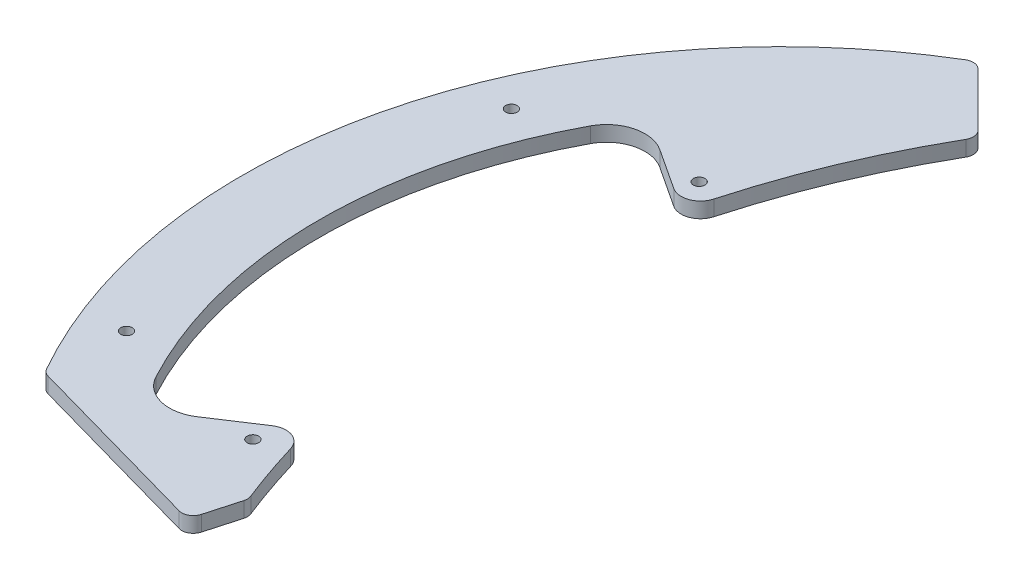
from build123d import *

# Parameters (mm, degrees)
SKETCH1_R               = 140
BOSS_EXTRUDE1_DEPTH     = 4
CUT_EXTRUDE1_REACH      = 6
CUT_EXTRUDE3_REACH      = 6
SKETCH19_R              = 1.5
CUT_EXTRUDE4_REACH      = 6
FILLET2_R               = 10
CUT_EXTRUDE8_DEPTH      = 1
CUT_EXTRUDE8_DEPTH_BACK = 5
CUT_EXTRUDE9_REACH      = 6
FILLET4_R               = 5
FILLET6_R               = 10
CUT_EXTRUDE10_REACH     = 6
SKETCH25_R              = 1.5
FILLET5_R               = 3


with BuildPart() as part:
    # Sketch1 → Boss-Extrude1 (new body)
    with BuildSketch(Plane(origin=(0, 0, 0), x_dir=(1, 0, 0), z_dir=(0, 1, 0))):
        Circle(SKETCH1_R)
    extrude(amount=BOSS_EXTRUDE1_DEPTH)

    # Sketch17 → Cut-Extrude1 (cut, up to next)
    with BuildSketch(Plane.XZ, mode=Mode.PRIVATE) as cut_extrude1_sk1:
        Polygon((-50, 90), (-121.24355653, 70), (-121.24355653, 140), (121.24355653, 140), (121.24355653, 70), (50, 90), align=None)
    cut_extrude1_tool1 = extrude(cut_extrude1_sk1.sketch, amount=-CUT_EXTRUDE1_REACH, mode=Mode.PRIVATE) & part.part
    add(cut_extrude1_tool1.solids().sort_by_distance((0, 0, 111.669853))[0], mode=Mode.SUBTRACT)

    # Sketch19 → Cut-Extrude3 (cut, up to next)
    with BuildSketch(Plane(origin=(0, 4, 0), x_dir=(1, 0, 0), z_dir=(0, 1, 0)), mode=Mode.PRIVATE) as cut_extrude3_sk1:
        with Locations((-79.195959493, -57.982756057)):
            Circle(SKETCH19_R)
    cut_extrude3_tool1 = extrude(cut_extrude3_sk1.sketch, amount=-CUT_EXTRUDE3_REACH, mode=Mode.PRIVATE) & part.part
    add(cut_extrude3_tool1.solids().sort_by_distance((-79.195959, 4, 57.982756))[0], mode=Mode.SUBTRACT)
    # Sketch19 → Cut-Extrude3 (cut, up to next)
    with BuildSketch(Plane(origin=(0, 4, 0), x_dir=(1, 0, 0), z_dir=(0, 1, 0)), mode=Mode.PRIVATE) as cut_extrude3_sk2:
        with Locations((-79.195959493, 57.982756057)):
            Circle(SKETCH19_R)
    cut_extrude3_tool2 = extrude(cut_extrude3_sk2.sketch, amount=-CUT_EXTRUDE3_REACH, mode=Mode.PRIVATE) & part.part
    add(cut_extrude3_tool2.solids().sort_by_distance((-79.195959, 4, -57.982756))[0], mode=Mode.SUBTRACT)
    # Sketch19 → Cut-Extrude3 (cut, up to next)
    with BuildSketch(Plane(origin=(0, 4, 0), x_dir=(1, 0, 0), z_dir=(0, 1, 0)), mode=Mode.PRIVATE) as cut_extrude3_sk3:
        with Locations((79.195959493, 57.982756057)):
            Circle(SKETCH19_R)
    cut_extrude3_tool3 = extrude(cut_extrude3_sk3.sketch, amount=-CUT_EXTRUDE3_REACH, mode=Mode.PRIVATE) & part.part
    add(cut_extrude3_tool3.solids().sort_by_distance((79.195959, 4, -57.982756))[0], mode=Mode.SUBTRACT)
    # Sketch19 → Cut-Extrude3 (cut, up to next)
    with BuildSketch(Plane(origin=(0, 4, 0), x_dir=(1, 0, 0), z_dir=(0, 1, 0)), mode=Mode.PRIVATE) as cut_extrude3_sk4:
        with Locations((79.195959493, -57.982756057)):
            Circle(SKETCH19_R)
    cut_extrude3_tool4 = extrude(cut_extrude3_sk4.sketch, amount=-CUT_EXTRUDE3_REACH, mode=Mode.PRIVATE) & part.part
    add(cut_extrude3_tool4.solids().sort_by_distance((79.195959, 4, 57.982756))[0], mode=Mode.SUBTRACT)
    # Sketch19 → Cut-Extrude3 (cut, up to next)
    with BuildSketch(Plane(origin=(0, 4, 0), x_dir=(1, 0, 0), z_dir=(0, 1, 0)), mode=Mode.PRIVATE) as cut_extrude3_sk5:
        with Locations((-57.982756057, 79.195959493)):
            Circle(SKETCH19_R)
    cut_extrude3_tool5 = extrude(cut_extrude3_sk5.sketch, amount=-CUT_EXTRUDE3_REACH, mode=Mode.PRIVATE) & part.part
    add(cut_extrude3_tool5.solids().sort_by_distance((-57.982756, 4, -79.195959))[0], mode=Mode.SUBTRACT)
    # Sketch19 → Cut-Extrude3 (cut, up to next)
    with BuildSketch(Plane(origin=(0, 4, 0), x_dir=(1, 0, 0), z_dir=(0, 1, 0)), mode=Mode.PRIVATE) as cut_extrude3_sk6:
        with Locations((57.982756057, 79.195959493)):
            Circle(SKETCH19_R)
    cut_extrude3_tool6 = extrude(cut_extrude3_sk6.sketch, amount=-CUT_EXTRUDE3_REACH, mode=Mode.PRIVATE) & part.part
    add(cut_extrude3_tool6.solids().sort_by_distance((57.982756, 4, -79.195959))[0], mode=Mode.SUBTRACT)
    # Sketch19 → Cut-Extrude3 (cut, up to next)
    with BuildSketch(Plane(origin=(0, 4, 0), x_dir=(1, 0, 0), z_dir=(0, 1, 0)), mode=Mode.PRIVATE) as cut_extrude3_sk7:
        with Locations((57.982756057, -79.195959493)):
            Circle(SKETCH19_R)
    cut_extrude3_tool7 = extrude(cut_extrude3_sk7.sketch, amount=-CUT_EXTRUDE3_REACH, mode=Mode.PRIVATE) & part.part
    add(cut_extrude3_tool7.solids().sort_by_distance((57.982756, 4, 79.195959))[0], mode=Mode.SUBTRACT)
    # Sketch19 → Cut-Extrude3 (cut, up to next)
    with BuildSketch(Plane(origin=(0, 4, 0), x_dir=(1, 0, 0), z_dir=(0, 1, 0)), mode=Mode.PRIVATE) as cut_extrude3_sk8:
        with Locations((-57.982756057, -79.195959493)):
            Circle(SKETCH19_R)
    cut_extrude3_tool8 = extrude(cut_extrude3_sk8.sketch, amount=-CUT_EXTRUDE3_REACH, mode=Mode.PRIVATE) & part.part
    add(cut_extrude3_tool8.solids().sort_by_distance((-57.982756, 4, 79.195959))[0], mode=Mode.SUBTRACT)

    # Sketch20 → Cut-Extrude4 (cut, up to next)
    with BuildSketch(Plane(origin=(0, 4, 0), x_dir=(1, 0, 0), z_dir=(0, 1, 0)), mode=Mode.PRIVATE) as cut_extrude4_sk1:
        Polygon((-498.316459894, 549.560016424), (-70, 121.24355653), (-50, 101.24355653), (50, 101.24355653), (70, 121.24355653), (498.316459894, 549.560016424), (498.316459894, 1761.021909565), (-498.316459894, 1761.021909565), align=None)
    cut_extrude4_tool1 = extrude(cut_extrude4_sk1.sketch, amount=-CUT_EXTRUDE4_REACH, mode=Mode.PRIVATE) & part.part
    add(cut_extrude4_tool1.solids().sort_by_distance((0, 4, -1025.243605))[0], mode=Mode.SUBTRACT)

    # Fillet2
    fillet2_edges = [part.edges().sort_by_distance(p)[0] for p in [
        (50, 2, -101.24355653),
        (-50, 2, -101.24355653),
    ]]
    fillet(fillet2_edges, radius=FILLET2_R)

    # Sketch23 → Cut-Extrude8 (cut, two sides)
    with BuildSketch(Plane(origin=(0, 4, 0), x_dir=(1, 0, 0), z_dir=(0, 1, 0))) as cut_extrude8_sk:
        with BuildLine():
            Line((261.924008605, 637.436261059), (-52.928932188, 104.172488718))
            ThreePointArc((-52.928932188, 104.172488718), (-80.130232259, 17.669229552), (-66.336519501, -71.95475195))
            Line((-66.336519501, -71.95475195), (-73.189737717, -96.367133919))
            Line((-73.189737717, -96.367133919), (-240.56703475, -692.594830068))
            Line((-240.56703475, -692.594830068), (918.053550165, -1130.326301498))
            Line((918.053550165, -1130.326301498), (1420.54459352, 199.704789628))
            Line((1420.54459352, 199.704789628), (261.924008605, 637.436261059))
        make_face()
    extrude(amount=CUT_EXTRUDE8_DEPTH, mode=Mode.SUBTRACT)
    extrude(cut_extrude8_sk.sketch, amount=-CUT_EXTRUDE8_DEPTH_BACK, mode=Mode.SUBTRACT)

    # Sketch24 → Cut-Extrude9 (cut, up to next)
    with BuildSketch(Plane(origin=(0, 4, 0), x_dir=(1, 0, 0), z_dir=(0, 1, 0)), mode=Mode.PRIVATE) as cut_extrude9_sk1:
        with BuildLine():
            Line((0, 0), (-100.308962252, 65.864346136))
            ThreePointArc((-100.308962252, 65.864346136), (-120, 0), (-100.308962252, -65.864346136))
            Line((-100.308962252, -65.864346136), (0, 0))
        make_face()
    cut_extrude9_tool1 = extrude(cut_extrude9_sk1.sketch, amount=-CUT_EXTRUDE9_REACH, mode=Mode.PRIVATE) & part.part
    add(cut_extrude9_tool1.solids().sort_by_distance((-75.574375, 4, 0))[0], mode=Mode.SUBTRACT)

    # Fillet4
    fillet4_edges = [part.edges().sort_by_distance(p)[0] for p in [
        (-74.063830686, 2, 48.63140512),
        (-75.142204111, 2, -49.339481038),
    ]]
    fillet(fillet4_edges, radius=FILLET4_R)

    # Fillet6
    fillet6_edges = [part.edges().sort_by_distance(p)[0] for p in [
        (-100.308962252, 2, 65.864346136),
        (-100.308962252, 2, -65.864346136),
    ]]
    fillet(fillet6_edges, radius=FILLET6_R)

    # Sketch25 → Cut-Extrude10 (cut, up to next)
    with BuildSketch(Plane(origin=(0, 4, 0), x_dir=(1, 0, 0), z_dir=(0, 1, 0)), mode=Mode.PRIVATE) as cut_extrude10_sk1:
        with Locations((-120, 50)):
            Circle(SKETCH25_R)
    cut_extrude10_tool1 = extrude(cut_extrude10_sk1.sketch, amount=-CUT_EXTRUDE10_REACH, mode=Mode.PRIVATE) & part.part
    add(cut_extrude10_tool1.solids().sort_by_distance((-120, 4, -50))[0], mode=Mode.SUBTRACT)
    # Sketch25 → Cut-Extrude10 (cut, up to next)
    with BuildSketch(Plane(origin=(0, 4, 0), x_dir=(1, 0, 0), z_dir=(0, 1, 0)), mode=Mode.PRIVATE) as cut_extrude10_sk2:
        with Locations((-120, -50)):
            Circle(SKETCH25_R)
    cut_extrude10_tool2 = extrude(cut_extrude10_sk2.sketch, amount=-CUT_EXTRUDE10_REACH, mode=Mode.PRIVATE) & part.part
    add(cut_extrude10_tool2.solids().sort_by_distance((-120, 4, 50))[0], mode=Mode.SUBTRACT)

    # Fillet5
    fillet5_edges = [part.edges().sort_by_distance(p)[0] for p in [
        (-121.24355653, 2, 70),
        (-70, 2, -121.24355653),
        (-52.928932188, 2, -104.172488718),
        (-69.838855295, 2, 84.430694855),
        (-66.336519501, 2, 71.95475195),
    ]]
    fillet(fillet5_edges, radius=FILLET5_R)


solid = part.part
